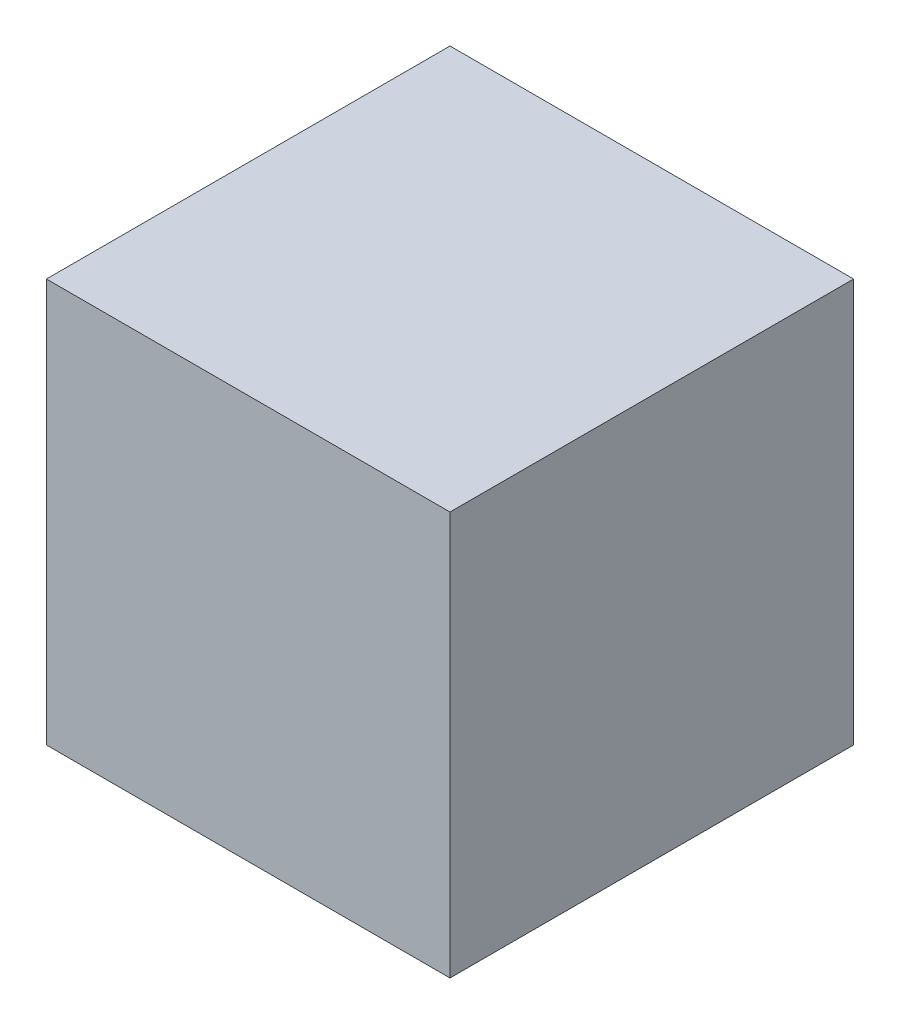
from build123d import *

# Parameters (mm, degrees)
SKETCH1_W           = 100
SKETCH1_H           = 100
BOSS_EXTRUDE1_DEPTH = 100


with BuildPart() as part:
    # Sketch1 → Boss-Extrude1 (new body)
    with BuildSketch(Plane(origin=(0, 0, 0), x_dir=(1, 0, 0), z_dir=(0, 1, 0))):
        Rectangle(SKETCH1_W, SKETCH1_H)
    extrude(amount=BOSS_EXTRUDE1_DEPTH)


solid = part.part
